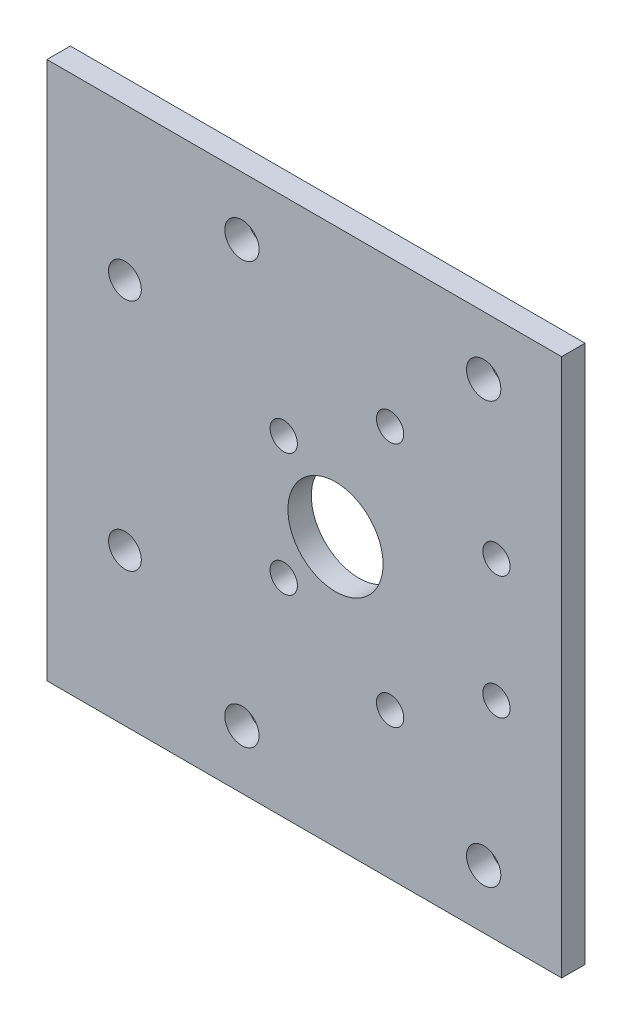
from build123d import *

# Parameters (mm, degrees)
SKETCH_1_W          = 40
SKETCH_1_H          = 29
EXTRUDE_1_DEPTH     = 3
SKETCH_3_W          = 40
SKETCH_3_H          = 3
EXTRUDE_2_DEPTH     = 10
SKETCH_4_W          = 40
SKETCH_4_H          = 3
EXTRUDE_3_DEPTH     = 10
SKETCH_6_W          = 3
SKETCH_6_H          = 49
EXTRUDE_5_DEPTH     = 42
SKETCH_8_W          = 3
SKETCH_8_H          = 49
EXTRUDE_6_DEPTH     = 2
SKETCH_9_W          = 3
SKETCH_9_H          = 49
EXTRUDE_7_DEPTH     = 2
SKETCH_10_W         = 86
SKETCH_10_H         = 3
EXTRUDE_8_DEPTH     = 10
SKETCH_11_W         = 86
SKETCH_11_H         = 3
EXTRUDE_9_DEPTH     = 10
SKETCH_12_R         = 2.2
CUT_EXTRUDE_3_DEPTH = 7.5
SKETCH_7_R          = 1.75
SKETCH_7_R_2        = 6.1
CUT_EXTRUDE_4_DEPTH = 10
SKETCH_13_R         = 2.1
CUT_EXTRUDE_5_DEPTH = 10
SKETCH_14_W         = 3
SKETCH_14_H         = 69
CUT_EXTRUDE_6_DEPTH = 20


with BuildPart() as part:
    # ｽｹｯﾁ1 → ﾎﾞｽ - 押し出し1 (new body)
    with BuildSketch(Plane.XY):
        Rectangle(SKETCH_1_W, SKETCH_1_H)
    extrude(amount=EXTRUDE_1_DEPTH)

    # ｽｹｯﾁ3 → ﾎﾞｽ - 押し出し2 (add)
    with BuildSketch(Plane.XZ.offset(14.5)):
        with Locations((0, 1.5)):
            Rectangle(SKETCH_3_W, SKETCH_3_H)
    extrude(amount=EXTRUDE_2_DEPTH)

    # ｽｹｯﾁ4 → ﾎﾞｽ - 押し出し3 (add)
    with BuildSketch(Plane(origin=(0, 14.5, 0), x_dir=(1, 0, 0), z_dir=(0, 1, 0))):
        with Locations((0, -1.5)):
            Rectangle(SKETCH_4_W, SKETCH_4_H)
    extrude(amount=EXTRUDE_3_DEPTH)

    # ｽｹｯﾁ6 → ﾎﾞｽ - 押し出し5 (add)
    with BuildSketch(Plane(origin=(20, 0, 0), x_dir=(0, 0, -1), z_dir=(1, 0, 0))):
        with Locations((-1.5, 0)):
            Rectangle(SKETCH_6_W, SKETCH_6_H)
    extrude(amount=EXTRUDE_5_DEPTH)

    # ｽｹｯﾁ8 → ﾎﾞｽ - 押し出し6 (add)
    with BuildSketch(Plane.ZY.offset(20)):
        with Locations((1.5, 0)):
            Rectangle(SKETCH_8_W, SKETCH_8_H)
    extrude(amount=EXTRUDE_6_DEPTH)

    # ｽｹｯﾁ9 → ﾎﾞｽ - 押し出し7 (add)
    with BuildSketch(Plane(origin=(62, 0, 0), x_dir=(0, 0, -1), z_dir=(1, 0, 0))):
        with Locations((-1.5, 0)):
            Rectangle(SKETCH_9_W, SKETCH_9_H)
    extrude(amount=EXTRUDE_7_DEPTH)

    # ｽｹｯﾁ10 → ﾎﾞｽ - 押し出し8 (add)
    with BuildSketch(Plane.XZ.offset(24.5)):
        with Locations((21, 1.5)):
            Rectangle(SKETCH_10_W, SKETCH_10_H)
    extrude(amount=EXTRUDE_8_DEPTH)

    # ｽｹｯﾁ11 → ﾎﾞｽ - 押し出し9 (add)
    with BuildSketch(Plane(origin=(0, 24.5, 0), x_dir=(1, 0, 0), z_dir=(0, 1, 0))):
        with Locations((21, -1.5)):
            Rectangle(SKETCH_11_W, SKETCH_11_H)
    extrude(amount=EXTRUDE_9_DEPTH)

    # ｽｹｯﾁ12 → ｶｯﾄ - 押し出し3 (cut)
    with BuildSketch(Plane.XY.offset(3)):
        with Locations((34, -27)):
            Circle(SKETCH_12_R)
        with Locations((34, 27)):
            Circle(SKETCH_12_R)
        with Locations((3, -27)):
            Circle(SKETCH_12_R)
        with Locations((3, 27)):
            Circle(SKETCH_12_R)
    extrude(amount=-CUT_EXTRUDE_3_DEPTH, mode=Mode.SUBTRACT)

    # ｽｹｯﾁ7 → ｶｯﾄ - 押し出し4 (cut)
    with BuildSketch(Plane.XY.offset(3)):
        with Locations((35.63990011, 7.875)):
            Circle(SKETCH_7_R)
        with Locations((35.63990011, -7.875)):
            Circle(SKETCH_7_R)
        with Locations((15, 0)):
            Circle(SKETCH_7_R_2)
        with Locations((22, 15.75)):
            Circle(SKETCH_7_R)
        with Locations((22, -15.75)):
            Circle(SKETCH_7_R)
        with Locations((8.36009989, 7.875)):
            Circle(SKETCH_7_R)
        with Locations((8.36009989, -7.875)):
            Circle(SKETCH_7_R)
    extrude(amount=-CUT_EXTRUDE_4_DEPTH, mode=Mode.SUBTRACT)

    # ｽｹｯﾁ13 → ｶｯﾄ - 押し出し5 (cut)
    with BuildSketch(Plane.XY.offset(3)):
        with Locations((-12, -15)):
            Circle(SKETCH_13_R)
        with Locations((-12, 15)):
            Circle(SKETCH_13_R)
    extrude(amount=-CUT_EXTRUDE_5_DEPTH, mode=Mode.SUBTRACT)

    # ｽｹｯﾁ14 → ｶｯﾄ - 押し出し6 (cut)
    with BuildSketch(Plane(origin=(64, 0, 0), x_dir=(0, 0, -1), z_dir=(1, 0, 0))):
        with Locations((-1.5, 0)):
            Rectangle(SKETCH_14_W, SKETCH_14_H)
    extrude(amount=-CUT_EXTRUDE_6_DEPTH, mode=Mode.SUBTRACT)


solid = part.part
